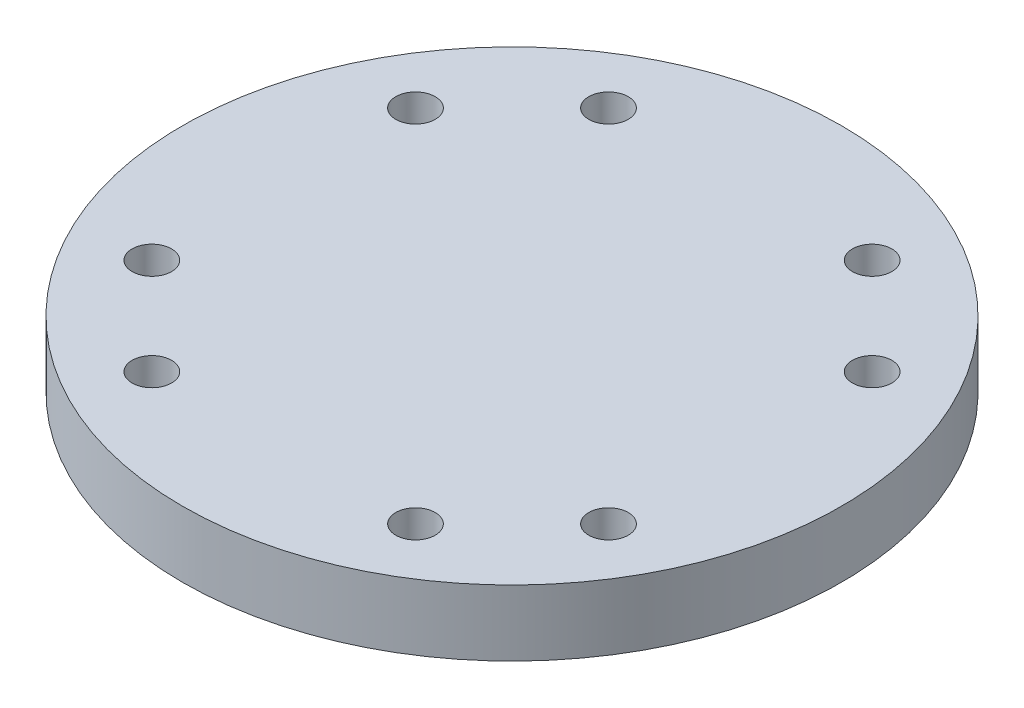
from build123d import *

# Parameters (mm, degrees)
SKETCH1_R           = 31.75
SKETCH1_R_2         = 1.90000001
BOSS_EXTRUDE1_DEPTH = 3.175


with BuildPart() as part:
    # Sketch1 → Boss-Extrude1 (new body, symmetric)
    with BuildSketch(Plane(origin=(0, 0, 0), x_dir=(1, 0, 0), z_dir=(0, 1, 0))):
        Circle(SKETCH1_R)
        with Locations((21.997045256, 12.7)):
            Circle(SKETCH1_R_2, mode=Mode.SUBTRACT)
        with Locations((21.997045256, -12.7)):
            Circle(SKETCH1_R_2, mode=Mode.SUBTRACT)
        with Locations((-12.7, -21.997045256)):
            Circle(SKETCH1_R_2, mode=Mode.SUBTRACT)
        with Locations((12.7, -21.997045256)):
            Circle(SKETCH1_R_2, mode=Mode.SUBTRACT)
        with Locations((-21.997045256, 12.7)):
            Circle(SKETCH1_R_2, mode=Mode.SUBTRACT)
        with Locations((-21.997045256, -12.7)):
            Circle(SKETCH1_R_2, mode=Mode.SUBTRACT)
        with Locations((12.7, 21.997045256)):
            Circle(SKETCH1_R_2, mode=Mode.SUBTRACT)
        with Locations((-12.7, 21.997045256)):
            Circle(SKETCH1_R_2, mode=Mode.SUBTRACT)
    extrude(amount=BOSS_EXTRUDE1_DEPTH, both=True)


solid = part.part
